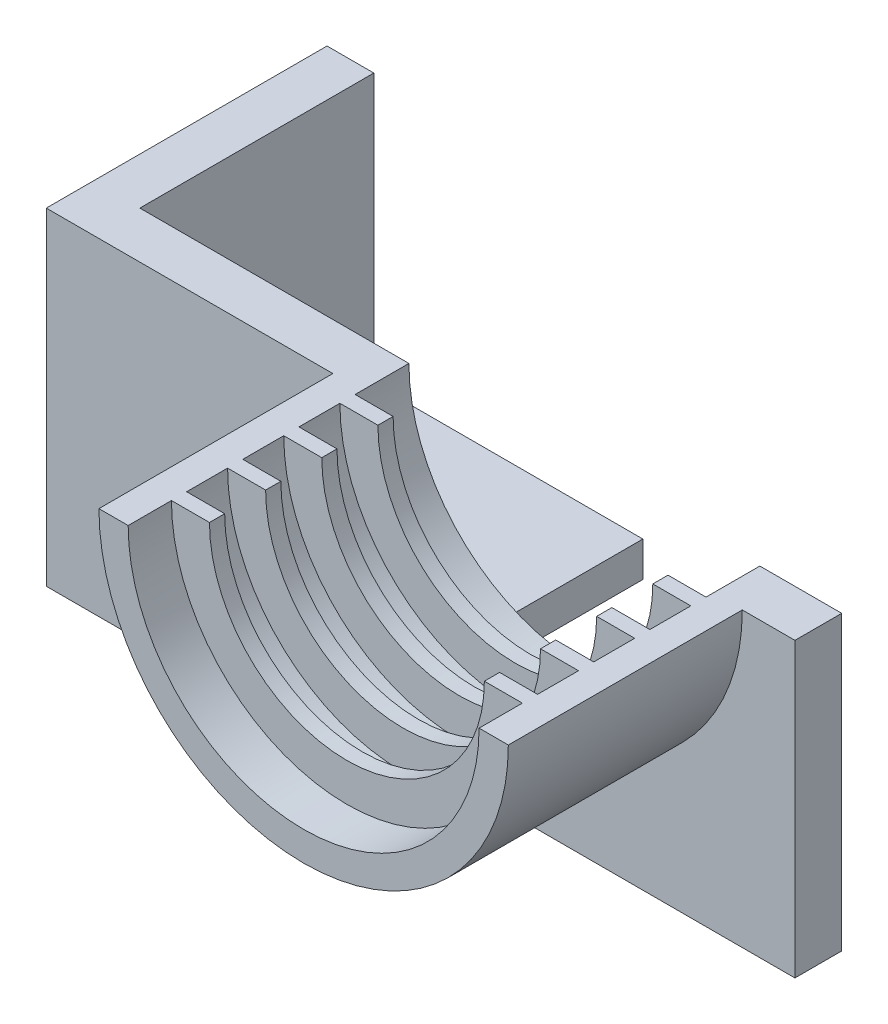
from build123d import *

# Parameters (mm, degrees)
SKETCH1_W            = 66
SKETCH1_H            = 33
BOSS_EXTRUDE1_DEPTH  = 4
CUT_EXTRUDE1_DEPTH   = 5
BOSS_EXTRUDE2_DEPTH  = 20
BOSS_EXTRUDE3_DEPTH  = 1.3
BOSS_EXTRUDE4_DEPTH  = 1.3
BOSS_EXTRUDE5_DEPTH  = 1.3
BOSS_EXTRUDE6_DEPTH  = 1.3
SKETCH11_W           = 66
SKETCH11_H           = 8
CUT_EXTRUDE4_DEPTH   = 10
SKETCH13_W           = 4
SKETCH13_H           = 25
BOSS_EXTRUDE7_DEPTH  = 9
SKETCH14_W           = 4
SKETCH14_H           = 25
BOSS_EXTRUDE8_DEPTH  = 8
SKETCH16_R           = 1.75
CUT_EXTRUDE5_DEPTH   = 12
SKETCH17_R           = 1.75
CUT_EXTRUDE8_DEPTH   = 12
SKETCH18_W           = 4
SKETCH18_H           = 25
CUT_EXTRUDE9_DEPTH   = 3
SKETCH19_W           = 4
SKETCH19_H           = 25
BOSS_EXTRUDE10_DEPTH = 4
SKETCH20_W           = 4
SKETCH20_H           = 25
BOSS_EXTRUDE11_DEPTH = 20
SKETCH21_R           = 1.75
CUT_EXTRUDE10_DEPTH  = 20
SKETCH22_W           = 20
SKETCH22_H           = 25
CUT_EXTRUDE11_DEPTH  = 20
SKETCH23_W           = 4
SKETCH23_H           = 25
BOSS_EXTRUDE12_DEPTH = 20
SKETCH24_R           = 1.75
CUT_EXTRUDE12_DEPTH  = 85
SKETCH25_W           = 25
SKETCH25_H           = 26
BOSS_EXTRUDE13_DEPTH = 3
SKETCH26_R           = 1.75
CUT_EXTRUDE13_DEPTH  = 29
SKETCH27_W           = 20
SKETCH27_H           = 25
CUT_EXTRUDE14_DEPTH  = 27


with BuildPart() as part:
    # Sketch1 → Boss-Extrude1 (new body)
    with BuildSketch(Plane.XY):
        with Locations((33, 16.5)):
            Rectangle(SKETCH1_W, SKETCH1_H)
    extrude(amount=BOSS_EXTRUDE1_DEPTH)

    # Sketch2 → Cut-Extrude1 (cut, through all)
    with BuildSketch(Plane.XY.offset(4)):
        with BuildLine():
            Line((18, 33), (48, 33))
            ThreePointArc((48, 33), (33, 18), (18, 33))
        make_face()
    extrude(amount=-CUT_EXTRUDE1_DEPTH, mode=Mode.SUBTRACT)

    # Sketch3 → Boss-Extrude2 (add)
    with BuildSketch(Plane.XY.offset(4)):
        with BuildLine():
            Line((18, 33), (15.5, 33))
            ThreePointArc((15.5, 33), (33, 15.5), (50.5, 33))
            Line((50.5, 33), (48, 33))
            ThreePointArc((48, 33), (33, 18), (18, 33))
        make_face()
    extrude(amount=BOSS_EXTRUDE2_DEPTH)

    # Sketch5 → Boss-Extrude3 (add)
    with BuildSketch(Plane.XY.offset(4.6)):
        with BuildLine():
            Line((18, 33), (21.25, 33))
            ThreePointArc((21.25, 33), (33, 21.25), (44.75, 33))
            Line((44.75, 33), (48, 33))
            ThreePointArc((48, 33), (33, 18), (18, 33))
        make_face()
    extrude(amount=BOSS_EXTRUDE3_DEPTH)

    # Sketch6 → Boss-Extrude4 (add)
    with BuildSketch(Plane.XY.offset(9.4)):
        with BuildLine():
            Line((18, 33), (21.25, 33))
            ThreePointArc((21.25, 33), (33, 21.25), (44.75, 33))
            Line((44.75, 33), (48, 33))
            ThreePointArc((48, 33), (33, 18), (18, 33))
        make_face()
    extrude(amount=BOSS_EXTRUDE4_DEPTH)

    # Sketch7 → Boss-Extrude5 (add)
    with BuildSketch(Plane.XY.offset(14.2)):
        with BuildLine():
            Line((18, 33), (21.25, 33))
            ThreePointArc((21.25, 33), (33, 21.25), (44.75, 33))
            Line((44.75, 33), (48, 33))
            ThreePointArc((48, 33), (33, 18), (18, 33))
        make_face()
    extrude(amount=BOSS_EXTRUDE5_DEPTH)

    # Sketch8 → Boss-Extrude6 (add)
    with BuildSketch(Plane.XY.offset(19)):
        with BuildLine():
            Line((18, 33), (21.25, 33))
            ThreePointArc((21.25, 33), (33, 21.25), (44.75, 33))
            Line((44.75, 33), (48, 33))
            ThreePointArc((48, 33), (33, 18), (18, 33))
        make_face()
    extrude(amount=BOSS_EXTRUDE6_DEPTH)

    # Sketch11 → Cut-Extrude4 (cut)
    with BuildSketch(Plane.XY.offset(4)):
        with Locations((33, 4)):
            Rectangle(SKETCH11_W, SKETCH11_H)
    extrude(amount=-CUT_EXTRUDE4_DEPTH, mode=Mode.SUBTRACT)

    # Sketch13 → Boss-Extrude7 (add)
    with BuildSketch(Plane.ZY):
        with Locations((2, 20.5)):
            Rectangle(SKETCH13_W, SKETCH13_H)
    extrude(amount=BOSS_EXTRUDE7_DEPTH)

    # Sketch14 → Boss-Extrude8 (add)
    with BuildSketch(Plane(origin=(66, 0, 0), x_dir=(0, 0, -1), z_dir=(1, 0, 0))):
        with Locations((-2, 20.5)):
            Rectangle(SKETCH14_W, SKETCH14_H)
    extrude(amount=BOSS_EXTRUDE8_DEPTH)

    # Sketch16 → Cut-Extrude5 (cut)
    with BuildSketch(Plane(origin=(74, 0, 0), x_dir=(0, 0, -1), z_dir=(1, 0, 0))):
        with Locations((14, 13)):
            Circle(SKETCH16_R)
    extrude(amount=-CUT_EXTRUDE5_DEPTH, mode=Mode.SUBTRACT)

    # Sketch17 → Cut-Extrude8 (cut)
    with BuildSketch(Plane.XY.offset(4)):
        with Locations((59, 13)):
            Circle(SKETCH17_R)
    extrude(amount=-CUT_EXTRUDE8_DEPTH, mode=Mode.SUBTRACT)

    # Sketch18 → Cut-Extrude9 (cut)
    with BuildSketch(Plane(origin=(74, 0, 0), x_dir=(0, 0, -1), z_dir=(1, 0, 0))):
        with Locations((-2, 20.5)):
            Rectangle(SKETCH18_W, SKETCH18_H)
    extrude(amount=-CUT_EXTRUDE9_DEPTH, mode=Mode.SUBTRACT)

    # Sketch19 → Boss-Extrude10 (add)
    with BuildSketch(Plane(origin=(71, 0, 0), x_dir=(0, 0, -1), z_dir=(1, 0, 0))):
        with Locations((-2, 20.5)):
            Rectangle(SKETCH19_W, SKETCH19_H)
    extrude(amount=BOSS_EXTRUDE10_DEPTH)

    # Sketch20 → Boss-Extrude11 (add)
    with BuildSketch(Plane(origin=(0, 0, 0), x_dir=(-1, 0, 0), z_dir=(0, 0, -1))):
        with Locations((-73, 20.5)):
            Rectangle(SKETCH20_W, SKETCH20_H)
    extrude(amount=BOSS_EXTRUDE11_DEPTH)

    # Sketch21 → Cut-Extrude10 (cut)
    with BuildSketch(Plane(origin=(75, 0, 0), x_dir=(0, 0, -1), z_dir=(1, 0, 0))):
        with Locations((14, 13)):
            Circle(SKETCH21_R)
    extrude(amount=-CUT_EXTRUDE10_DEPTH, mode=Mode.SUBTRACT)

    # Sketch22 → Cut-Extrude11 (cut)
    with BuildSketch(Plane(origin=(75, 0, 0), x_dir=(0, 0, -1), z_dir=(1, 0, 0))):
        with Locations((10, 20.5)):
            Rectangle(SKETCH22_W, SKETCH22_H)
    extrude(amount=-CUT_EXTRUDE11_DEPTH, mode=Mode.SUBTRACT)

    # Sketch23 → Boss-Extrude12 (add)
    with BuildSketch(Plane(origin=(0, 0, 0), x_dir=(-1, 0, 0), z_dir=(0, 0, -1))):
        with Locations((7, 20.5)):
            Rectangle(SKETCH23_W, SKETCH23_H)
    extrude(amount=BOSS_EXTRUDE12_DEPTH)

    # Sketch24 → Cut-Extrude12 (cut, through all)
    with BuildSketch(Plane.ZY.offset(9)):
        with Locations((-7.5, 20)):
            Circle(SKETCH24_R)
    extrude(amount=-CUT_EXTRUDE12_DEPTH, mode=Mode.SUBTRACT)

    # Sketch25 → Boss-Extrude13 (add)
    with BuildSketch(Plane(origin=(0, 8, 0), x_dir=(-1, 0, 0), z_dir=(0, -1, 0))):
        with Locations((-3.5, 9)):
            Rectangle(SKETCH25_W, SKETCH25_H)
    extrude(amount=BOSS_EXTRUDE13_DEPTH)

    # Sketch26 → Cut-Extrude13 (cut, through all)
    with BuildSketch(Plane(origin=(0, 5, 0), x_dir=(-1, 0, 0), z_dir=(0, -1, 0))):
        with Locations((-7, 7.5)):
            Circle(SKETCH26_R)
    extrude(amount=-CUT_EXTRUDE13_DEPTH, mode=Mode.SUBTRACT)

    # Sketch27 → Cut-Extrude14 (cut, through all)
    with BuildSketch(Plane.XY.offset(4)):
        with Locations((65, 20.5)):
            Rectangle(SKETCH27_W, SKETCH27_H)
    extrude(amount=-CUT_EXTRUDE14_DEPTH, mode=Mode.SUBTRACT)


solid = part.part
